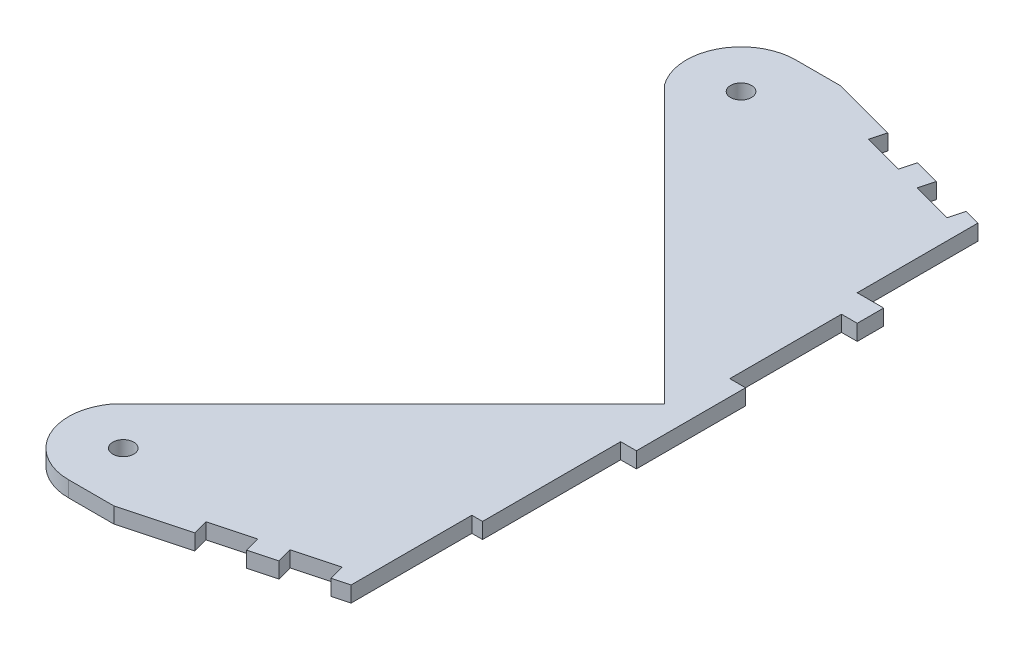
from build123d import *

# Parameters (mm, degrees)
SKETCH1_R           = 3.175
BOSS_EXTRUDE1_DEPTH = 4.7625
SKETCH3_W           = 4.7625
SKETCH3_H           = 33.783
SKETCH3_H_2         = 46.289475607
CUT_EXTRUDE2_DEPTH  = 10


with BuildPart() as part:
    # Sketch1 → Boss-Extrude1 (new body)
    with BuildSketch(Plane(origin=(0, 0, 0), x_dir=(1, 0, 0), z_dir=(0, 1, 0))):
        with BuildLine():
            Line((0, 0), (-83.629476528, 83.629476528))
            ThreePointArc((-83.629476528, 83.629476528), (-85.081850373, 100.91197572), (-70.310188895, 110))
            Line((-70.310188895, 110), (-56.601944845, 110))
            Line((-56.601944845, 110), (0, 94.833554589))
            Line((0, 94.833554589), (0, 58.293))
            Line((0, 58.293), (8, 58.293))
            Line((8, 58.293), (8, -58.293))
            Line((8, -58.293), (0, -58.293))
            Line((0, -58.293), (0, -94.833554589))
            Line((0, -94.833554589), (-56.601944845, -110))
            Line((-56.601944845, -110), (-70.310188895, -110))
            ThreePointArc((-70.310188895, -110), (-85.081850373, -100.91197572), (-83.629476528, -83.629476528))
            Line((-83.629476528, -83.629476528), (0, 0))
        make_face()
        with Locations((-70.310188895, 93.451069294)):
            Circle(SKETCH1_R, mode=Mode.SUBTRACT)
        with Locations((-70.310188895, -93.451069294)):
            Circle(SKETCH1_R, mode=Mode.SUBTRACT)
    extrude(amount=BOSS_EXTRUDE1_DEPTH)

    # Sketch3 → Cut-Extrude2 (cut)
    with BuildSketch(Plane(origin=(0, 0, 0), x_dir=(1, 0, 0), z_dir=(0, 1, 0))):
        Polygon((-4.829629131, 96.127649814), (-17.19282542, 99.440358276), (-18.425451123, 94.840136528), (-6.062254834, 91.527428067), align=None)
        Polygon((-24.920232031, 101.510910637), (-37.283428319, 104.823619098), (-38.516054022, 100.22339735), (-26.152857733, 96.910688889), align=None)
        with Locations((5.61875, 33.4015)):
            Rectangle(SKETCH3_W, SKETCH3_H)
        Polygon((-26.152857733, -96.910688889), (-38.516054022, -100.22339735), (-37.283428319, -104.823619098), (-24.920232031, -101.510910637), align=None)
        Polygon((-6.062254834, -91.527428067), (-18.425451123, -94.840136528), (-17.19282542, -99.440358276), (-4.829629131, -96.127649814), align=None)
        with Locations((5.61875, -39.654737804)):
            Rectangle(SKETCH3_W, SKETCH3_H_2)
    extrude(amount=CUT_EXTRUDE2_DEPTH, mode=Mode.SUBTRACT)


solid = part.part
